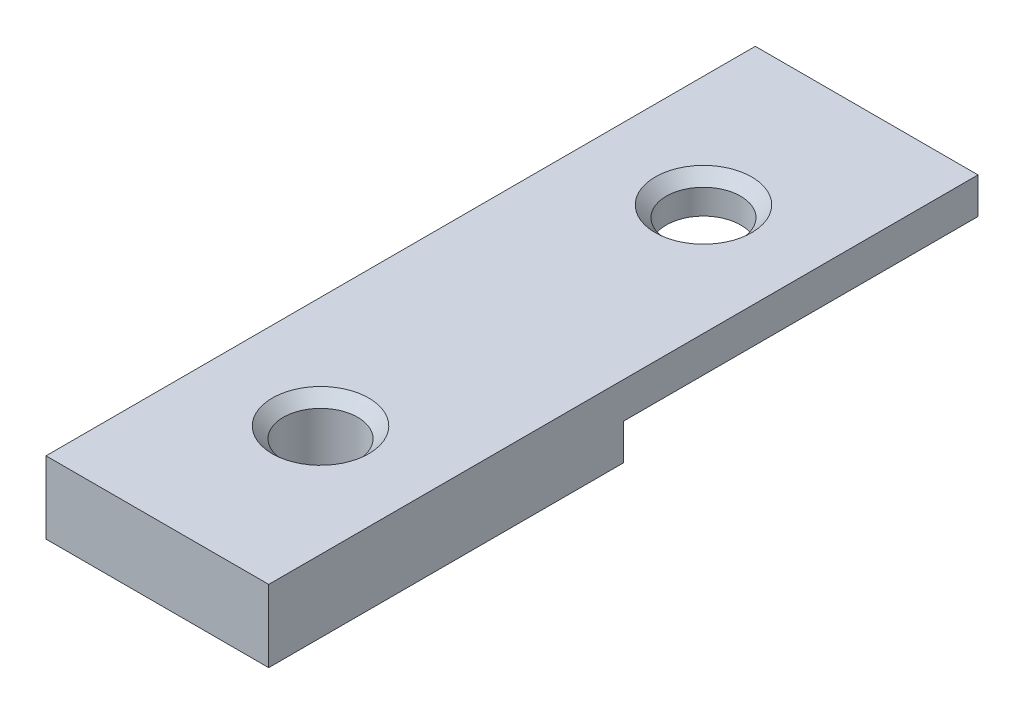
from build123d import *

# Parameters (mm, degrees)
SKETCH1_W           = 20.06486665
SKETCH1_H           = 63.9
SKETCH1_R           = 3.35
BOSS_EXTRUDE1_DEPTH = 6.5
CHAMFER1_SIZE       = 1
SKETCH2_W           = 31.95
SKETCH2_H           = 3.25
CUT_EXTRUDE1_DEPTH  = 21.06486665


with BuildPart() as part:
    # Sketch1 → Boss-Extrude1 (new body)
    with BuildSketch(Plane(origin=(0, 0, 0), x_dir=(1, 0, 0), z_dir=(0, 1, 0))):
        with Locations((-10.582433325, -32.5)):
            Rectangle(SKETCH1_W, SKETCH1_H)
        with Locations((-10.582433325, -15.25)):
            Circle(SKETCH1_R, mode=Mode.SUBTRACT)
        with Locations((-10.582433325, -49.75)):
            Circle(SKETCH1_R, mode=Mode.SUBTRACT)
    extrude(amount=BOSS_EXTRUDE1_DEPTH)

    # Chamfer1
    chamfer1_edges = [part.edges().sort_by_distance(p)[0] for p in [
        (-13.932433325, 6.5, 15.25),
        (-13.932433325, 6.5, 49.75),
    ]]
    chamfer(chamfer1_edges, length=CHAMFER1_SIZE)

    # Sketch2 → Cut-Extrude1 (cut, through all)
    with BuildSketch(Plane(origin=(-0.55, 0, 0), x_dir=(0, 0, -1), z_dir=(1, 0, 0))):
        with Locations((-16.525, 1.625)):
            Rectangle(SKETCH2_W, SKETCH2_H)
    extrude(amount=-CUT_EXTRUDE1_DEPTH, mode=Mode.SUBTRACT)


solid = part.part
